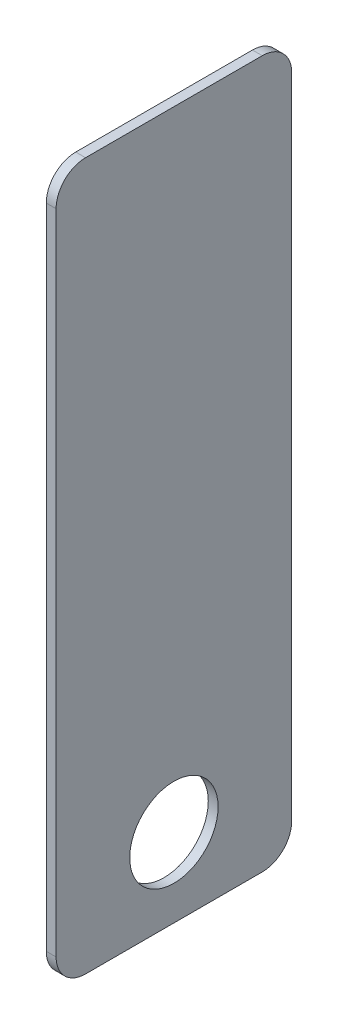
from build123d import *

# Parameters (mm, degrees)
SKETCH1_W           = 76.2
SKETCH1_H           = 228.6
SKETCH1_R           = 14.2875
BOSS_EXTRUDE1_DEPTH = 3.175
FILLET1_R           = 9.525


with BuildPart() as part:
    # Sketch1 → Boss-Extrude1 (new body)
    with BuildSketch(Plane(origin=(0, 0, 0), x_dir=(0, 0, -1), z_dir=(1, 0, 0))):
        Rectangle(SKETCH1_W, SKETCH1_H)
        with Locations((0, -88.9)):
            Circle(SKETCH1_R, mode=Mode.SUBTRACT)
    extrude(amount=BOSS_EXTRUDE1_DEPTH)

    # Fillet1
    fillet1_edges = [part.edges().sort_by_distance(p)[0] for p in [
        (1.5875, 114.3, 38.1),
        (1.5875, 114.3, -38.1),
        (1.5875, -114.3, -38.1),
        (1.5875, -114.3, 38.1),
    ]]
    fillet(fillet1_edges, radius=FILLET1_R)


solid = part.part
